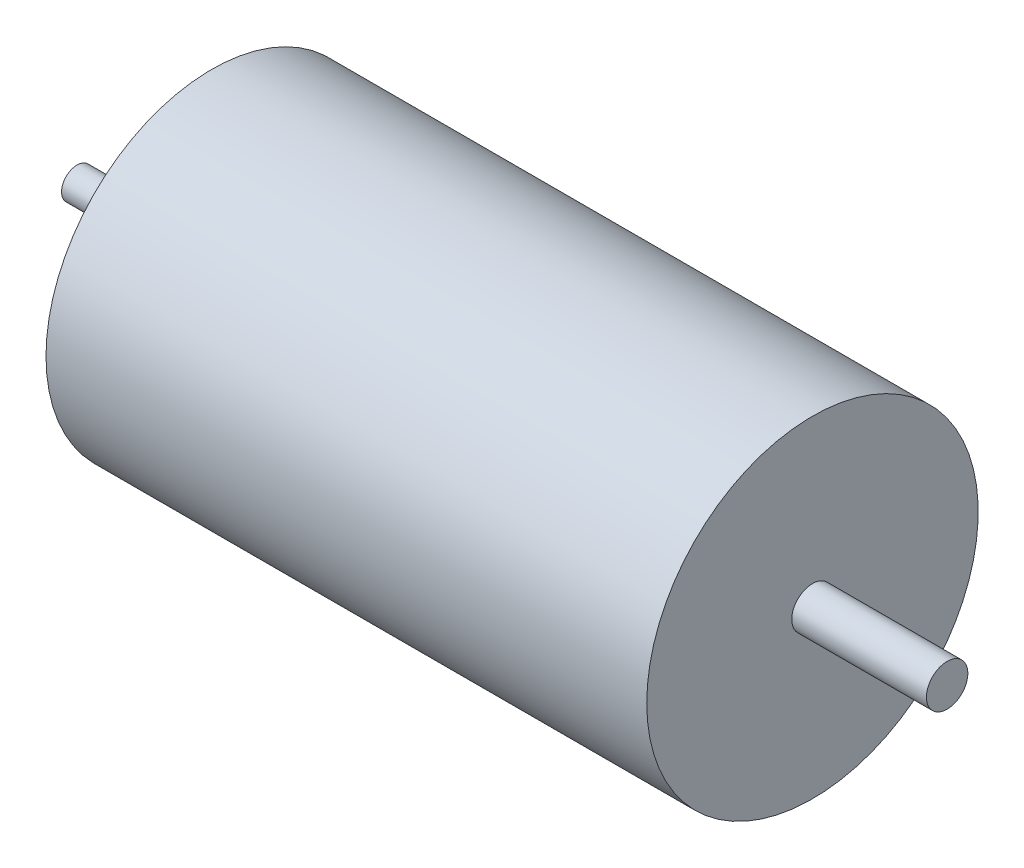
from build123d import *

# Parameters (mm, degrees)
TROU_TARAUD_M2_5X0_451_D           = 2.05
TROU_TARAUD_M2_5X0_451_DEPTH       = 7.25
TROU_TARAUD_M2_5X0_451_CSINK_D     = 2.55
TROU_TARAUD_M2_5X0_451_CSINK_ANGLE = 90
TROU_TARAUD_M2_5X0_451_TIP         = 0.615882135


with BuildPart() as part:
    # Esquisse1 → Révolution1 (revolve)
    with BuildSketch(Plane.XY):
        Polygon((0, 16), (58, 16), (58, 2), (71, 2), (71, 0), (-13, 0), (-13, 1.5), (-3, 1.5), (-3, 6.5), (0, 6.5), align=None)
    revolve(axis=Axis((-42.470383275, 0, 0), (1, 0, 0)))

    # Trou taraudé M2.5x0.451
    with Locations(Plane.ZY):
        with Locations((0, 9.5), (-8.227241336, -4.75), (8.227241336, -4.75), (0, -9.5)):
            CounterSinkHole(TROU_TARAUD_M2_5X0_451_D / 2, TROU_TARAUD_M2_5X0_451_CSINK_D / 2, depth=TROU_TARAUD_M2_5X0_451_DEPTH, counter_sink_angle=TROU_TARAUD_M2_5X0_451_CSINK_ANGLE)
            with Locations((0, 0, -(TROU_TARAUD_M2_5X0_451_DEPTH + TROU_TARAUD_M2_5X0_451_TIP / 2))):  # 118° drill point
                Cone(0, TROU_TARAUD_M2_5X0_451_D / 2, TROU_TARAUD_M2_5X0_451_TIP, mode=Mode.SUBTRACT)


solid = part.part
